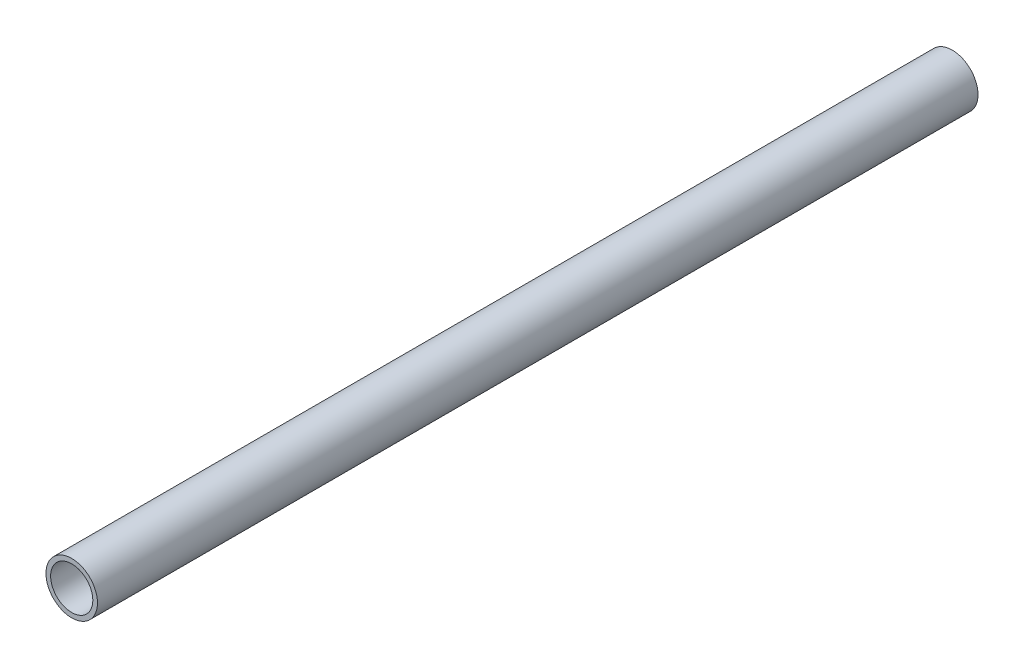
from build123d import *

# Parameters (mm, degrees)
SZKIC1_R                         = 7.75
SZKIC1_R_2                       = 6.35
DODANIE_WYCI_GNI_CIE1_DEPTH      = 219.716847891
DODANIE_WYCI_GNI_CIE1_DEPTH_BACK = 45.204307067


with BuildPart() as part:
    # Szkic1 → Dodanie-wyciągnięcie1 (new body, two sides)
    with BuildSketch(Plane.XY) as dodanie_wyci_gni_cie1_sk:
        Circle(SZKIC1_R)
        Circle(SZKIC1_R_2, mode=Mode.SUBTRACT)
    extrude(amount=DODANIE_WYCI_GNI_CIE1_DEPTH)
    extrude(dodanie_wyci_gni_cie1_sk.sketch, amount=-DODANIE_WYCI_GNI_CIE1_DEPTH_BACK)


solid = part.part
